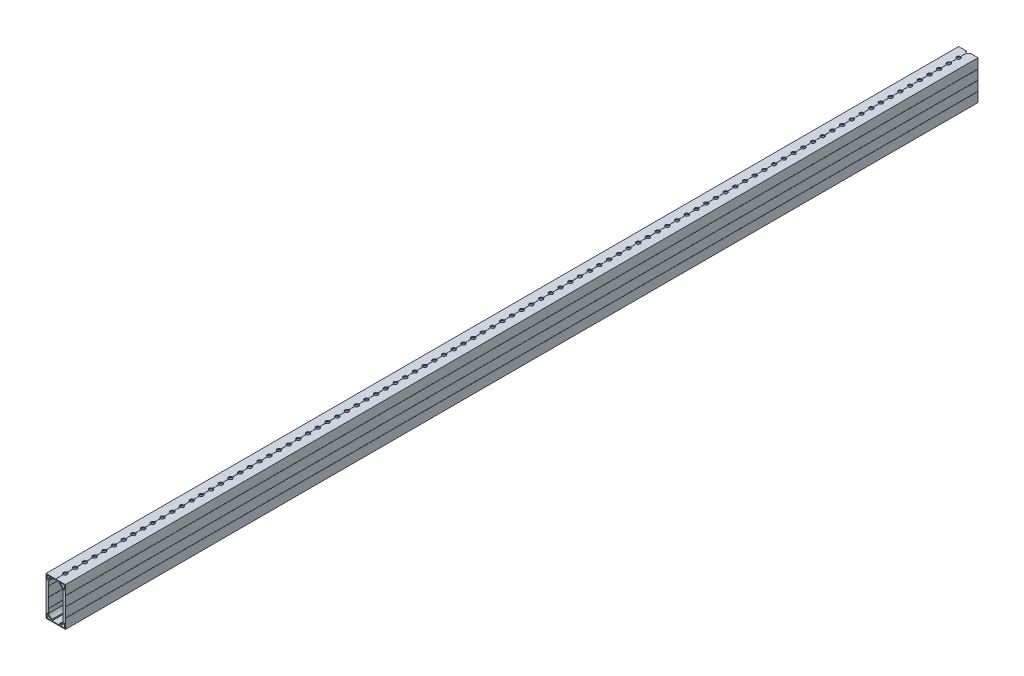
from build123d import *

# Parameters (mm, degrees)
SKETCH1_W                                = 50.8
SKETCH1_H                                = 1193.8
BOSS_EXTRUDE1_DEPTH                      = 25.4
CUT_EXTRUDE1_DEPTH                       = 1194.8
CUT_EXTRUDE9_DEPTH                       = 1194.8
MIRROR1_AT_THE_SECOND_PLANE_COPY_1_DEPTH = 1194.8
SKETCH18_R                               = 2.54
CUT_EXTRUDE12_DEPTH                      = 51.8
LPATTERN1_COUNT                          = 94
LPATTERN1_PITCH                          = 12.7
FILLET1_R                                = 0.127


with BuildPart() as part:
    # Sketch1 → Boss-Extrude1 (new body)
    with BuildSketch(Plane(origin=(-12.7, 0, 0), x_dir=(0, -1, 0), z_dir=(-1, 0, 0))):
        Rectangle(SKETCH1_W, SKETCH1_H)
    extrude(amount=-BOSS_EXTRUDE1_DEPTH)

    # Sketch2 → Cut-Extrude1 (cut, through all)
    with BuildSketch(Plane(origin=(0, 0, -596.9), x_dir=(-1, 0, 0), z_dir=(0, 0, -1))):
        Polygon((-12.7, -12.573), (-12.7, -12.827), (-12.573, -12.7), align=None)
        Polygon((-0.127, 0), (0.127, 0), (0, 0.127), align=None)
        Polygon((12.7, -12.827), (12.7, -12.573), (12.573, -12.7), align=None)
        Polygon((-12.7, 0.127), (-12.7, -0.127), (-12.573, 0), align=None)
        Polygon((-12.7, 12.827), (-12.7, 12.573), (-12.573, 12.7), align=None)
        Polygon((12.7, -0.127), (12.7, 0.127), (12.573, 0), align=None)
        Polygon((12.7, 12.573), (12.7, 12.827), (12.573, 12.7), align=None)
        Polygon((-0.127, 25.4), (0.127, 25.4), (0, 25.273), align=None)
    extrude(amount=-CUT_EXTRUDE1_DEPTH, mode=Mode.SUBTRACT)

    # Sketch10 → Cut-Extrude9 (cut, through all)
    with BuildSketch(Plane.XY.offset(596.9)):
        with BuildLine():
            Line((-11.684, 24.384), (-11.684, 19.297089026))
            ThreePointArc((-11.684, 19.297089026), (-11.177055919, 18.630604499), (-10.39941737, 18.941204261))
            ThreePointArc((-10.39941737, 18.941204261), (-8.576144596, 21.276144596), (-6.241204261, 23.09941737))
            ThreePointArc((-6.241204261, 23.09941737), (-5.930604499, 23.877055919), (-6.597089026, 24.384))
            Line((-6.597089026, 24.384), (-11.684, 24.384))
        make_face()
        Polygon((-12.7, 0.127), (-12.7, 0), (-12.573, 0), align=None)
        Polygon((-12.7, 12.827), (-12.573, 12.7), (-12.7, 12.573), align=None)
        Polygon((0.127, 25.4), (0, 25.273), (-0.127, 25.4), align=None)
        with BuildLine():
            Line((0, 24.384), (-4.8895, 24.384))
            Line((-4.8895, 24.384), (-4.8895, 22.679000251))
            ThreePointArc((-4.8895, 22.679000251), (-7.514726072, 20.886363558), (-9.525, 18.42381265))
            Line((-9.525, 18.42381265), (-9.525, 12.827))
            Line((-9.525, 12.827), (-9.652, 12.7))
            Line((-9.652, 12.7), (-9.525, 12.573))
            Line((-9.525, 12.573), (-9.525, 0.127))
            Line((-9.525, 0.127), (-9.652, 0))
            Line((-9.652, 0), (0, 0))
            Line((0, 0), (0, 24.384))
        make_face()
    cut_extrude9 = extrude(amount=-CUT_EXTRUDE9_DEPTH, mode=Mode.SUBTRACT)

    # Mirror1: Cut-Extrude9 across plane
    add(cut_extrude9.mirror(Plane.ZX), mode=Mode.SUBTRACT)

    # Mirror1 at the second plane: Cut-Extrude9 across plane
    add(cut_extrude9.mirror(Plane(origin=(0, 0, 0), x_dir=(0, 0, 1), z_dir=(1, 0, 0))), mode=Mode.SUBTRACT)

    # Mirror1 at the second plane copy 1 sketc → Mirror1 at the second plane copy 1 (cut, through all)
    with BuildSketch(Plane(origin=(0, 0, 596.9), x_dir=(-1, 0, 0), z_dir=(0, 0, 1))):
        with BuildLine():
            Line((-11.684, 24.384), (-11.684, 19.297089026))
            ThreePointArc((-11.684, 19.297089026), (-11.177055919, 18.630604499), (-10.39941737, 18.941204261))
            ThreePointArc((-10.39941737, 18.941204261), (-8.576144596, 21.276144596), (-6.241204261, 23.09941737))
            ThreePointArc((-6.241204261, 23.09941737), (-5.930604499, 23.877055919), (-6.597089026, 24.384))
            Line((-6.597089026, 24.384), (-11.684, 24.384))
        make_face()
        Polygon((-12.7, 0.127), (-12.7, 0), (-12.573, 0), align=None)
        Polygon((-12.7, 12.827), (-12.573, 12.7), (-12.7, 12.573), align=None)
        Polygon((0.127, 25.4), (0, 25.273), (-0.127, 25.4), align=None)
        with BuildLine():
            Line((0, 24.384), (-4.8895, 24.384))
            Line((-4.8895, 24.384), (-4.8895, 22.679000251))
            ThreePointArc((-4.8895, 22.679000251), (-7.514726072, 20.886363558), (-9.525, 18.42381265))
            Line((-9.525, 18.42381265), (-9.525, 12.827))
            Line((-9.525, 12.827), (-9.652, 12.7))
            Line((-9.652, 12.7), (-9.525, 12.573))
            Line((-9.525, 12.573), (-9.525, 0.127))
            Line((-9.525, 0.127), (-9.652, 0))
            Line((-9.652, 0), (0, 0))
            Line((0, 0), (0, 24.384))
        make_face()
    extrude(amount=-MIRROR1_AT_THE_SECOND_PLANE_COPY_1_DEPTH, mode=Mode.SUBTRACT)

    # Sketch18 → Cut-Extrude12 (cut, through all)
    with BuildSketch(Plane(origin=(0, 25.4, 0), x_dir=(1, 0, 0), z_dir=(0, 1, 0))):
        with Locations((0, -584.2)):
            Circle(SKETCH18_R)
    cut_extrude12 = extrude(amount=-CUT_EXTRUDE12_DEPTH, mode=Mode.SUBTRACT)

    # LPattern1: Cut-Extrude12 ×94
    with Locations(*[(0, 0, -i * LPATTERN1_PITCH) for i in range(1, LPATTERN1_COUNT)]):
        add(cut_extrude12, mode=Mode.SUBTRACT)

    # Fillet1
    fillet1_edges = [part.edges().sort_by_distance(p)[0] for p in [
        (-4.8895, 22.679000251, 0),
        (-4.8895, 24.384, 0),
        (-9.525, 18.42381265, 0),
        (4.8895, 24.384, 0),
        (4.8895, 22.679000251, 0),
        (9.525, 18.42381265, 0),
        (-4.8895, -24.384, 0),
        (-4.8895, -22.679000251, 0),
        (-9.525, -18.42381265, 0),
        (4.8895, -22.679000251, 0),
        (4.8895, -24.384, 0),
        (9.525, -18.42381265, 0),
    ]]
    fillet(fillet1_edges, radius=FILLET1_R)


solid = part.part
